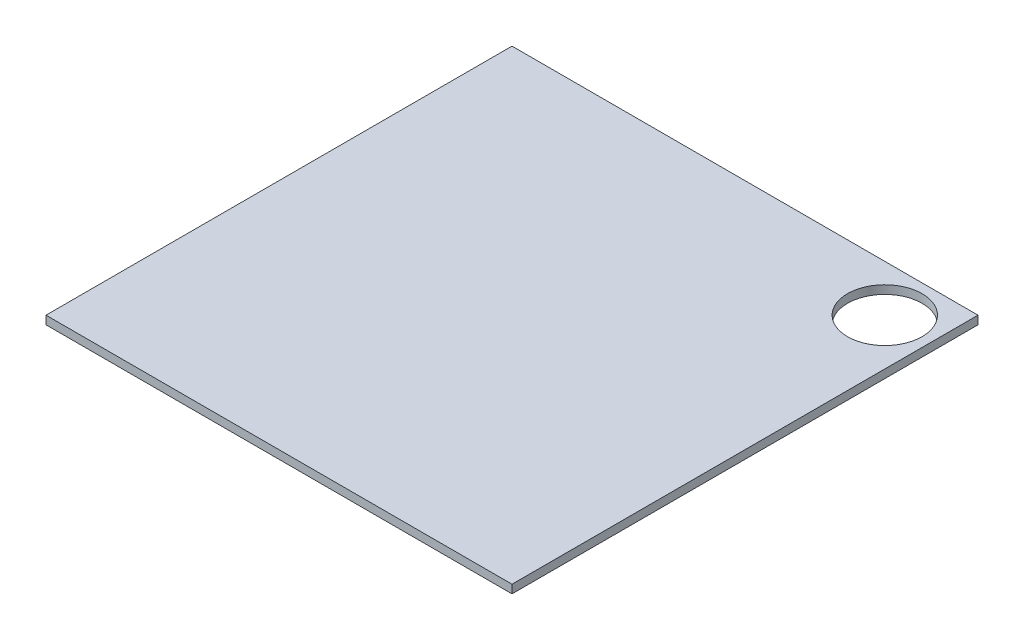
from build123d import *

# Parameters (mm, degrees)
SKETCH_1_W          = 100
SKETCH_1_H          = 100
EXTRUDE_1_DEPTH     = 1.8
SKETCH_2_R          = 8
CUT_EXTRUDE_1_DEPTH = 2.8


with BuildPart() as part:
    # 草图1 → 凸台-拉伸1 (new body)
    with BuildSketch(Plane(origin=(0, 0, 0), x_dir=(1, 0, 0), z_dir=(0, 1, 0))):
        with Locations((50, 50)):
            Rectangle(SKETCH_1_W, SKETCH_1_H)
    extrude(amount=EXTRUDE_1_DEPTH)

    # 草图2 → 切除-拉伸1 (cut, through all)
    with BuildSketch(Plane(origin=(0, 1.8, 0), x_dir=(1, 0, 0), z_dir=(0, 1, 0))):
        with Locations((90, 90)):
            Circle(SKETCH_2_R)
    extrude(amount=-CUT_EXTRUDE_1_DEPTH, mode=Mode.SUBTRACT)


solid = part.part
